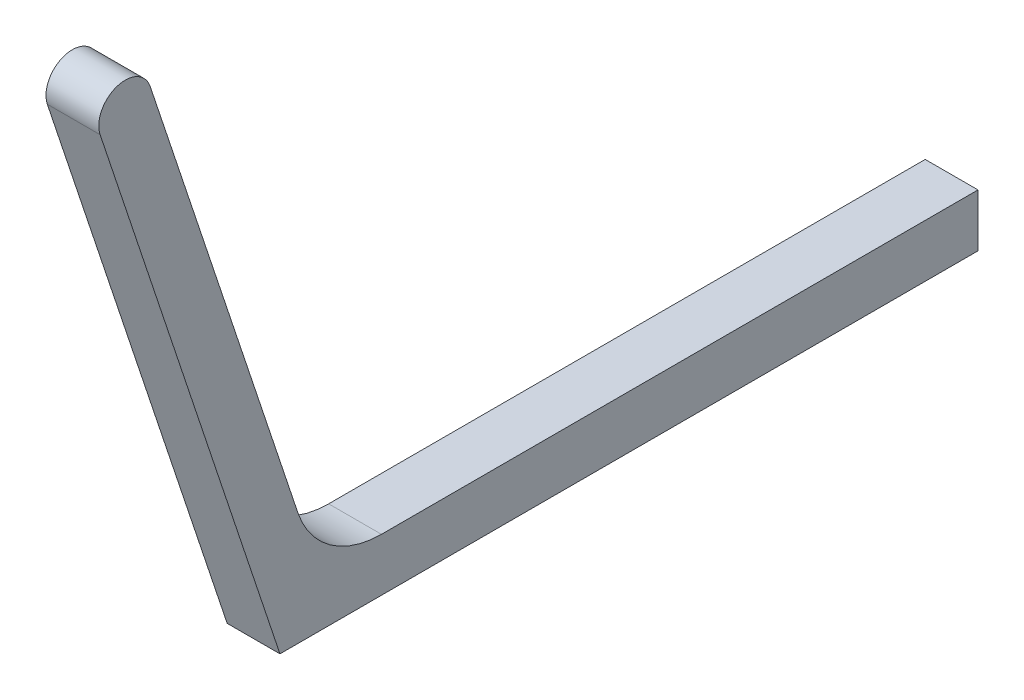
from build123d import *

# Parameters (mm, degrees)
SALIENTE_EXTRUIR1_DEPTH = 6


with BuildPart() as part:
    # Croquis1 → Saliente-Extruir1 (new body)
    with BuildSketch(Plane(origin=(3, 0, 0), x_dir=(0, 0, -1), z_dir=(1, 0, 0))):
        with BuildLine():
            Line((-143.367600492, 342.71356838), (-122.930987198, 281.403728499))
            Line((-122.930987198, 281.403728499), (-43.606431878, 281.403728499))
            Line((-43.606431878, 281.403728499), (-43.606431878, 287.403728499))
            Line((-43.606431878, 287.403728499), (-111.398839678, 287.403728499))
            ThreePointArc((-111.398839678, 287.403728499), (-117.245942524, 289.291306647), (-120.885672658, 294.241450839))
            Line((-120.885672658, 294.241450839), (-137.675500704, 344.610934976))
            ThreePointArc((-137.675500704, 344.610934976), (-141.470233896, 346.508301573), (-143.367600492, 342.71356838))
        make_face()
    extrude(amount=-SALIENTE_EXTRUIR1_DEPTH)


solid = part.part
